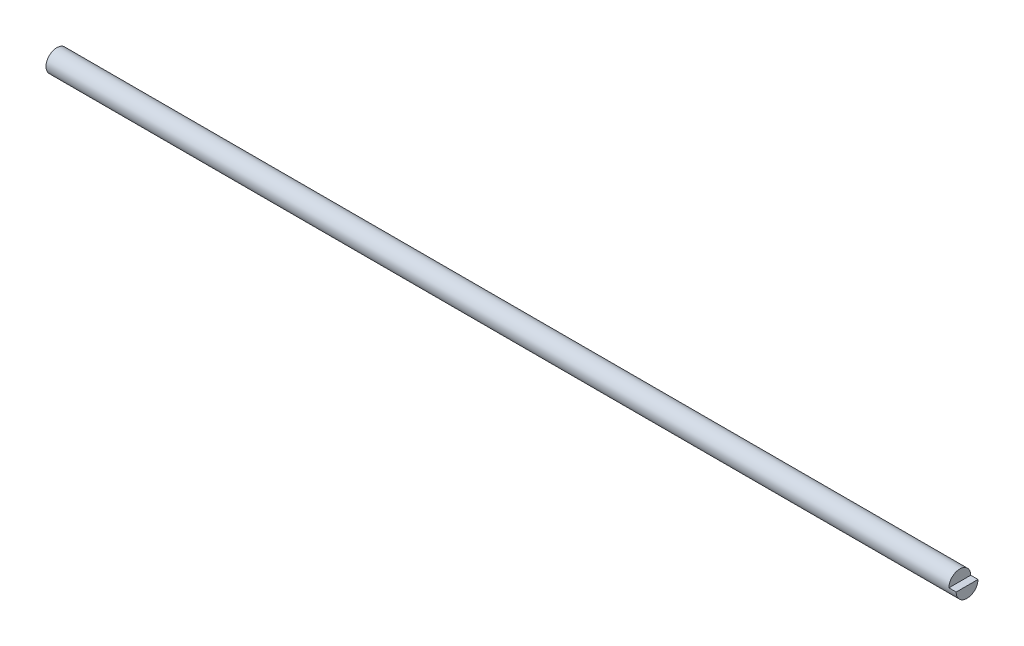
from build123d import *

# Parameters (mm, degrees)
SKETCH1_R           = 3.81
BOSS_EXTRUDE1_DEPTH = 317.5
CUT_EXTRUDE1_DEPTH  = 2.54


with BuildPart() as part:
    # Sketch1 → Boss-Extrude1 (new body)
    with BuildSketch(Plane(origin=(0, 0, 0), x_dir=(0, 0, -1), z_dir=(1, 0, 0))):
        Circle(SKETCH1_R)
    extrude(amount=BOSS_EXTRUDE1_DEPTH)

    # Sketch2 → Cut-Extrude1 (cut)
    with BuildSketch(Plane(origin=(317.5, 0, 0), x_dir=(0, 0, -1), z_dir=(1, 0, 0))):
        with BuildLine():
            Line((-3.81, 0), (3.81, 0))
            ThreePointArc((3.81, 0), (0, 3.81), (-3.81, 0))
        make_face()
    extrude(amount=-CUT_EXTRUDE1_DEPTH, mode=Mode.SUBTRACT)


solid = part.part
